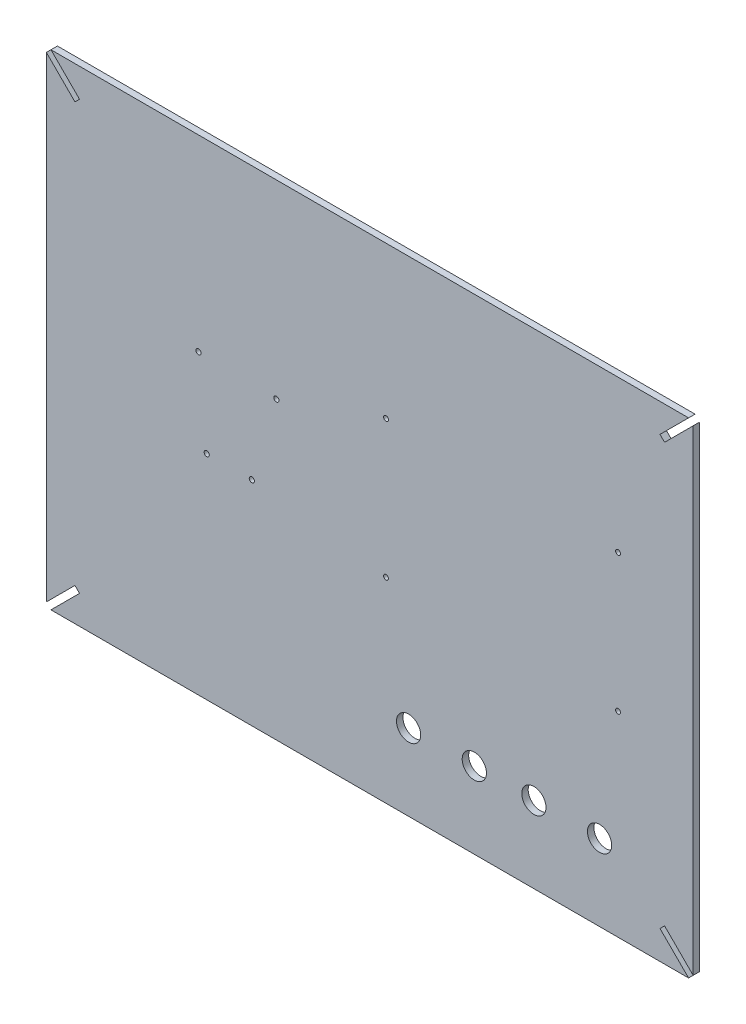
from build123d import *

# Parameters (mm, degrees)
ESQUISSE1_R        = 1.5
ESQUISSE1_R_2      = 7.5
ESQUISSE1_R_3      = 1.6
BOSS_EXTRU_1_DEPTH = 4


with BuildPart() as part:
    # Esquisse1 → Boss.-Extru.1 (new body)
    with BuildSketch(Plane.XY):
        Polygon((-443.856361675, 119.15022686), (-49.513215925, 119.15022686), (-67.190885454, 101.472557331), (-64.36245833, 98.644130206), (-46.6847888, 116.321799736), (-46.6847888, -178.021346015), (-64.36245833, -160.343676485), (-67.190885454, -163.17210361), (-49.513215925, -180.84977314), (-443.856361675, -180.84977314), (-426.178692146, -163.17210361), (-429.00711927, -160.343676485), (-446.6847888, -178.021346015), (-446.6847888, 116.321799736), (-429.00711927, 98.644130206), (-426.178692146, 101.472557331), align=None)
        with Locations((-236.6397888, 25.29522686)):
            Circle(ESQUISSE1_R, mode=Mode.SUBTRACT)
        with Locations((-93.1297888, 25.29522686)):
            Circle(ESQUISSE1_R, mode=Mode.SUBTRACT)
        with Locations((-236.6397888, -59.79477314)):
            Circle(ESQUISSE1_R, mode=Mode.SUBTRACT)
        with Locations((-93.1297888, -59.79477314)):
            Circle(ESQUISSE1_R, mode=Mode.SUBTRACT)
        with Locations((-104.5597888, -133.60477314)):
            Circle(ESQUISSE1_R_2, mode=Mode.SUBTRACT)
        with Locations((-347.5347888, -49.04977314)):
            Circle(ESQUISSE1_R_3, mode=Mode.SUBTRACT)
        with Locations((-319.6347888, -49.04977314)):
            Circle(ESQUISSE1_R_3, mode=Mode.SUBTRACT)
        with Locations((-352.6347888, 3.05022686)):
            Circle(ESQUISSE1_R_3, mode=Mode.SUBTRACT)
        with Locations((-304.4347888, 1.75022686)):
            Circle(ESQUISSE1_R_3, mode=Mode.SUBTRACT)
        with Locations((-145.1997888, -133.60477314)):
            Circle(ESQUISSE1_R_2, mode=Mode.SUBTRACT)
        with Locations((-182.0297888, -133.60477314)):
            Circle(ESQUISSE1_R_2, mode=Mode.SUBTRACT)
        with Locations((-222.6697888, -133.60477314)):
            Circle(ESQUISSE1_R_2, mode=Mode.SUBTRACT)
    extrude(amount=BOSS_EXTRU_1_DEPTH)


solid = part.part
